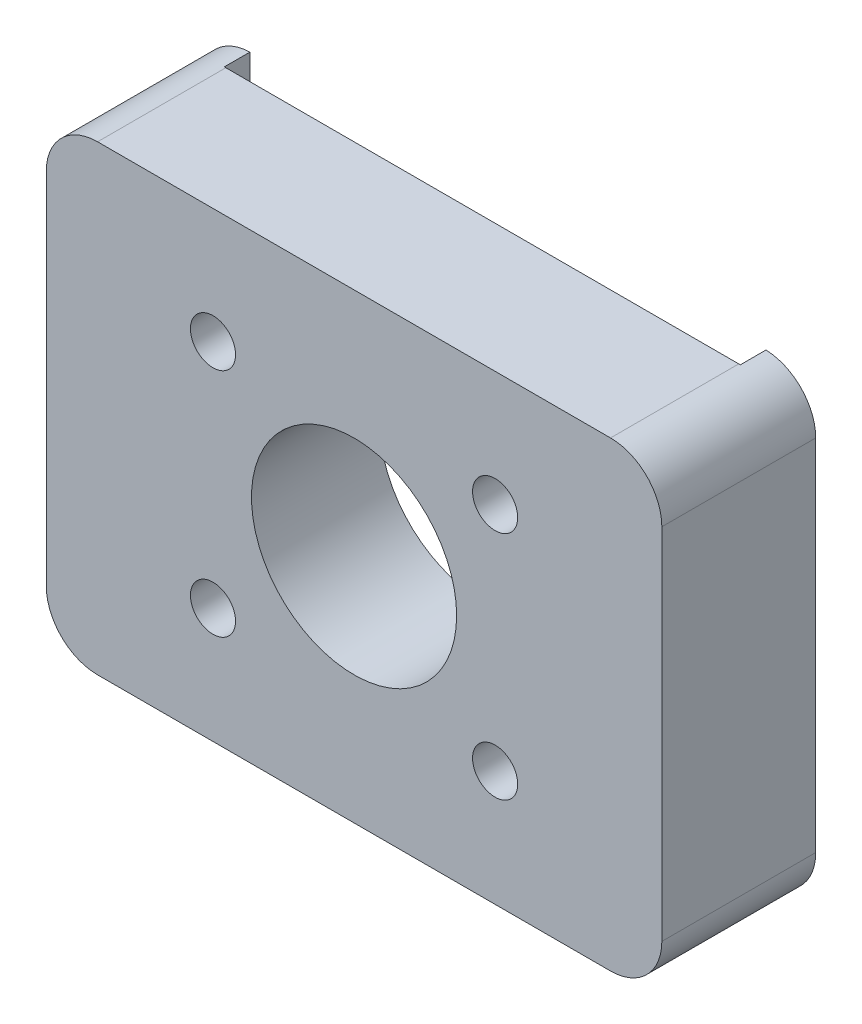
from build123d import *

# Parameters (mm, degrees)
SKETCH1_R           = 4.4
SKETCH1_R_2         = 20
BOSS_EXTRUDE1_DEPTH = 25
BOSS_EXTRUDE2_DEPTH = 5


with BuildPart() as part:
    # Sketch1 → Boss-Extrude1 (new body)
    with BuildSketch(Plane.XY):
        with BuildLine():
            Line((-50, 45), (50, 45))
            ThreePointArc((50, 45), (57.071067812, 42.071067812), (60, 35))
            Line((60, 35), (60, -35))
            ThreePointArc((60, -35), (57.071067812, -42.071067812), (50, -45))
            Line((50, -45), (-50, -45))
            ThreePointArc((-50, -45), (-57.071067812, -42.071067812), (-60, -35))
            Line((-60, -35), (-60, 35))
            ThreePointArc((-60, 35), (-57.071067812, 42.071067812), (-50, 45))
        make_face()
        with Locations((-27.5, 22.5)):
            Circle(SKETCH1_R, mode=Mode.SUBTRACT)
        with Locations((27.5, 22.5)):
            Circle(SKETCH1_R, mode=Mode.SUBTRACT)
        with Locations((-27.5, -22.5)):
            Circle(SKETCH1_R, mode=Mode.SUBTRACT)
        with Locations((27.5, -22.5)):
            Circle(SKETCH1_R, mode=Mode.SUBTRACT)
        Circle(SKETCH1_R_2, mode=Mode.SUBTRACT)
    extrude(amount=BOSS_EXTRUDE1_DEPTH)

    # Sketch2 → Boss-Extrude2 (add)
    with BuildSketch(Plane(origin=(0, 0, 0), x_dir=(-1, 0, 0), z_dir=(0, 0, -1))):
        with BuildLine():
            Line((-50.3, 44.995498987), (-50.3, -44.995498987))
            ThreePointArc((-50.3, -44.995498987), (-57.176350047, -41.964194139), (-60, -35))
            Line((-60, -35), (-60, 35))
            ThreePointArc((-60, 35), (-57.176350047, 41.964194139), (-50.3, 44.995498987))
        make_face()
        with BuildLine():
            Line((60, -35), (60, 35))
            ThreePointArc((60, 35), (57.176350047, 41.964194139), (50.3, 44.995498987))
            Line((50.3, 44.995498987), (50.3, -44.995498987))
            ThreePointArc((50.3, -44.995498987), (57.176350047, -41.964194139), (60, -35))
        make_face()
    extrude(amount=BOSS_EXTRUDE2_DEPTH)


solid = part.part
